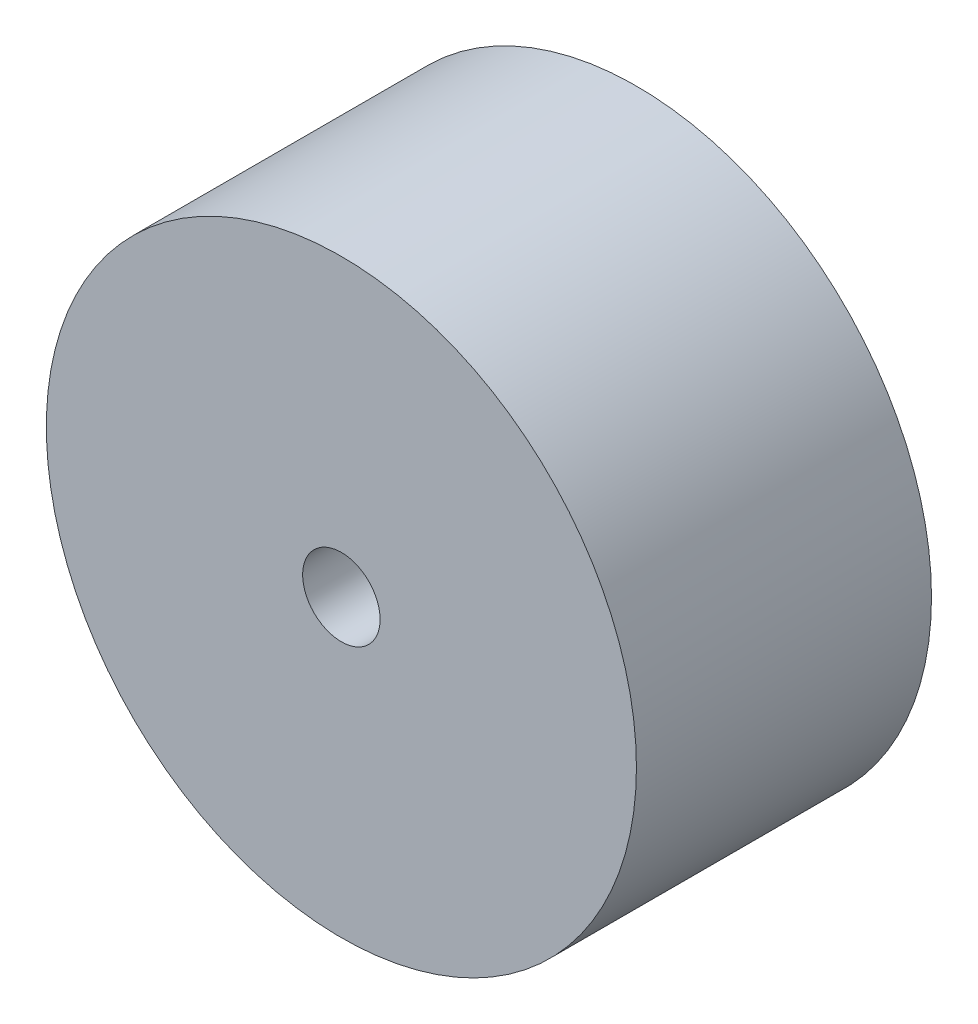
from build123d import *

# Parameters (mm, degrees)
SKETCH1_R           = 19.05
SKETCH1_R_2         = 2.5
BOSS_EXTRUDE1_DEPTH = 19.05


with BuildPart() as part:
    # Sketch1 → Boss-Extrude1 (new body)
    with BuildSketch(Plane.XY):
        Circle(SKETCH1_R)
        Circle(SKETCH1_R_2, mode=Mode.SUBTRACT)
    extrude(amount=BOSS_EXTRUDE1_DEPTH)


solid = part.part
